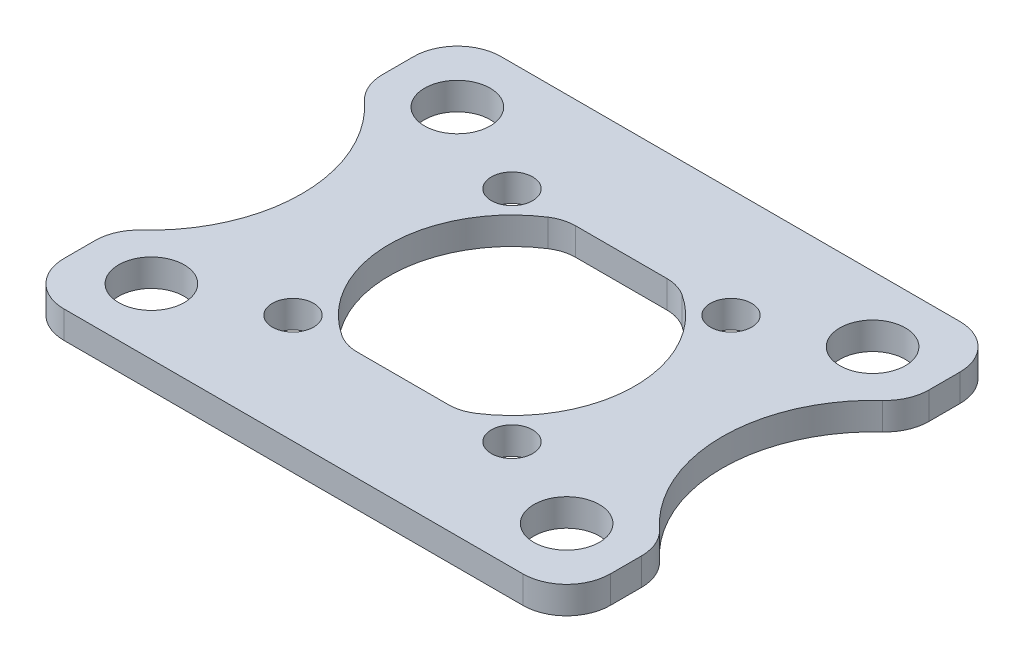
from build123d import *

# Parameters (mm, degrees)
SKETCH1_W           = 31.75
SKETCH1_H           = 25.4
SKETCH1_R           = 7.1374
SKETCH1_R_2         = 1.2
SKETCH1_R_3         = 1.905
BOSS_EXTRUDE1_DEPTH = 1.5875
BOSS_EXTRUDE3_DEPTH = 1.5875
CUT_EXTRUDE1_DEPTH  = 2.5875
FILLET3_R           = 2.54
FILLET2_R           = 2.286


with BuildPart() as part:
    # Sketch1 → Boss-Extrude1 (new body)
    with BuildSketch(Plane(origin=(0, 0, 0), x_dir=(1, 0, 0), z_dir=(0, 1, 0))):
        Rectangle(SKETCH1_W, SKETCH1_H)
        Circle(SKETCH1_R, mode=Mode.SUBTRACT)
        with Locations((-6.363961031, -6.363961031)):
            Circle(SKETCH1_R_2, mode=Mode.SUBTRACT)
        with Locations((-6.363961031, 6.363961031)):
            Circle(SKETCH1_R_2, mode=Mode.SUBTRACT)
        with Locations((6.363961031, 6.363961031)):
            Circle(SKETCH1_R_2, mode=Mode.SUBTRACT)
        with Locations((6.363961031, -6.363961031)):
            Circle(SKETCH1_R_2, mode=Mode.SUBTRACT)
        with Locations((-12.065, -8.89)):
            Circle(SKETCH1_R_3, mode=Mode.SUBTRACT)
        with Locations((-12.065, 8.89)):
            Circle(SKETCH1_R_3, mode=Mode.SUBTRACT)
        with Locations((12.065, 8.89)):
            Circle(SKETCH1_R_3, mode=Mode.SUBTRACT)
        with Locations((12.065, -8.89)):
            Circle(SKETCH1_R_3, mode=Mode.SUBTRACT)
    extrude(amount=BOSS_EXTRUDE1_DEPTH)

    # Sketch3 → Boss-Extrude3 (add, through all)
    with BuildSketch(Plane(origin=(0, 1.5875, 0), x_dir=(1, 0, 0), z_dir=(0, 1, 0))):
        with BuildLine():
            Line((-3.258830889, 6.35), (3.258830889, 6.35))
            ThreePointArc((3.258830889, 6.35), (0, 7.1374), (-3.258830889, 6.35))
        make_face()
        with BuildLine():
            Line((3.258830889, -6.35), (-3.258830889, -6.35))
            ThreePointArc((-3.258830889, -6.35), (0, -7.1374), (3.258830889, -6.35))
        make_face()
    extrude(amount=-BOSS_EXTRUDE3_DEPTH)

    # Sketch4 → Cut-Extrude1 (cut, through all)
    with BuildSketch(Plane.XZ):
        with BuildLine():
            Line((-15.875, 7.152704943), (-15.875, -7.152704943))
            ThreePointArc((-15.875, -7.152704943), (-12.2174, 0), (-15.875, 7.152704943))
        make_face()
        with BuildLine():
            Line((15.875, -7.152704943), (15.875, 7.152704943))
            ThreePointArc((15.875, 7.152704943), (12.2174, 0), (15.875, -7.152704943))
        make_face()
    extrude(amount=-CUT_EXTRUDE1_DEPTH, mode=Mode.SUBTRACT)

    # Fillet3
    fillet3_edges = [part.edges().sort_by_distance(p)[0] for p in [
        (-15.875, 0.79375, 7.152704943),
        (-15.875, 0.79375, -7.152704943),
        (15.875, 0.79375, 12.7),
        (-15.875, 0.79375, 12.7),
        (15.875, 0.79375, -7.152704943),
        (-15.875, 0.79375, -12.7),
        (15.875, 0.79375, 7.152704943),
        (15.875, 0.79375, -12.7),
    ]]
    fillet(fillet3_edges, radius=FILLET3_R)

    # Fillet2
    fillet2_edges = [part.edges().sort_by_distance(p)[0] for p in [
        (-3.258830889, 0.79375, -6.35),
        (3.258830889, 0.79375, -6.35),
        (3.258830889, 0.79375, 6.35),
        (-3.258830889, 0.79375, 6.35),
    ]]
    fillet(fillet2_edges, radius=FILLET2_R)


solid = part.part
